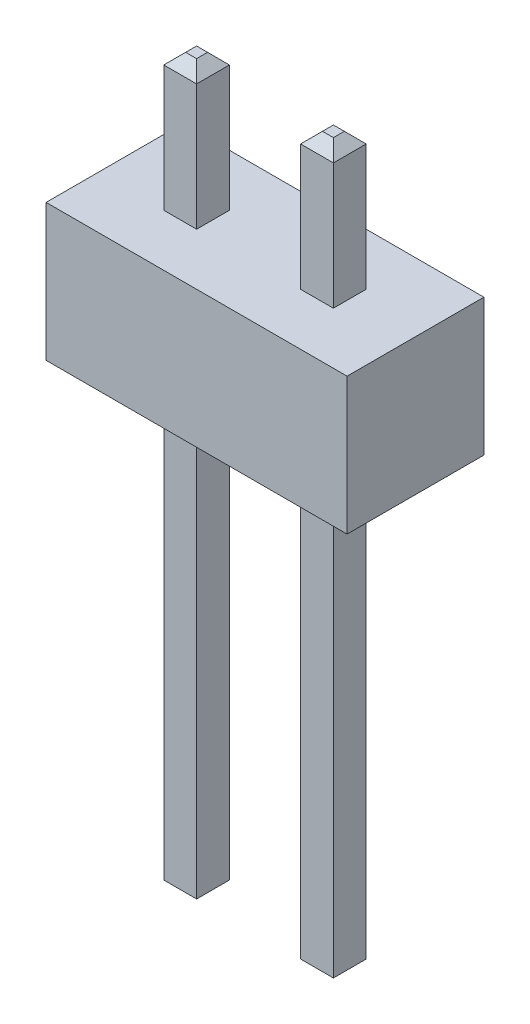
from build123d import *

# Parameters (mm, degrees)
SKETCH1_W                = 5.5
SKETCH1_H                = 2.5
BOSS_EXTRUDE1_DEPTH      = 2.5
BOSS_EXTRUDE2_START      = -10.8
SKETCH2_W                = 0.6
SKETCH2_H                = 0.6
BOSS_EXTRUDE2_DEPTH      = 13.3
CHAMFER1_SIZE            = 0.2
CHAMFER1_OF_MIRROR1_SIZE = 0.2


with BuildPart() as part:
    # Sketch1 → Boss-Extrude1 (new body)
    with BuildSketch(Plane(origin=(0, 0, 0), x_dir=(1, 0, 0), z_dir=(0, 1, 0))):
        Rectangle(SKETCH1_W, SKETCH1_H)
    extrude(amount=BOSS_EXTRUDE1_DEPTH)

    # Sketch2 → Boss-Extrude2 (add)
    with BuildSketch(Plane(origin=(0, 2.5, 0), x_dir=(1, 0, 0), z_dir=(0, 1, 0)).offset(BOSS_EXTRUDE2_START)):
        with Locations((-1.25, 0)):
            Rectangle(SKETCH2_W, SKETCH2_H)
    boss_extrude2 = extrude(amount=BOSS_EXTRUDE2_DEPTH)

    # Chamfer1
    chamfer1_edges = [part.edges().sort_by_distance(p)[0] for p in [
        (-1.55, -8.3, 0),
        (-1.25, -8.3, -0.3),
        (-0.95, -8.3, 0),
        (-1.25, -8.3, 0.3),
        (-1.55, 5, 0),
        (-1.25, 5, 0.3),
        (-0.95, 5, 0),
        (-1.25, 5, -0.3),
    ]]
    chamfer(chamfer1_edges, length=CHAMFER1_SIZE)

    # Mirror1: Boss-Extrude2 across plane
    add(boss_extrude2.mirror(Plane(origin=(0, 0, 0), x_dir=(0, 0, 1), z_dir=(1, 0, 0))))

    # Chamfer1 of Mirror1
    chamfer1_of_mirror1_edges = [part.edges().sort_by_distance(p)[0] for p in [
        (1.55, -8.3, 0),
        (1.25, -8.3, -0.3),
        (0.95, -8.3, 0),
        (1.25, -8.3, 0.3),
        (1.55, 5, 0),
        (1.25, 5, 0.3),
        (0.95, 5, 0),
        (1.25, 5, -0.3),
    ]]
    chamfer(chamfer1_of_mirror1_edges, length=CHAMFER1_OF_MIRROR1_SIZE)


solid = part.part
